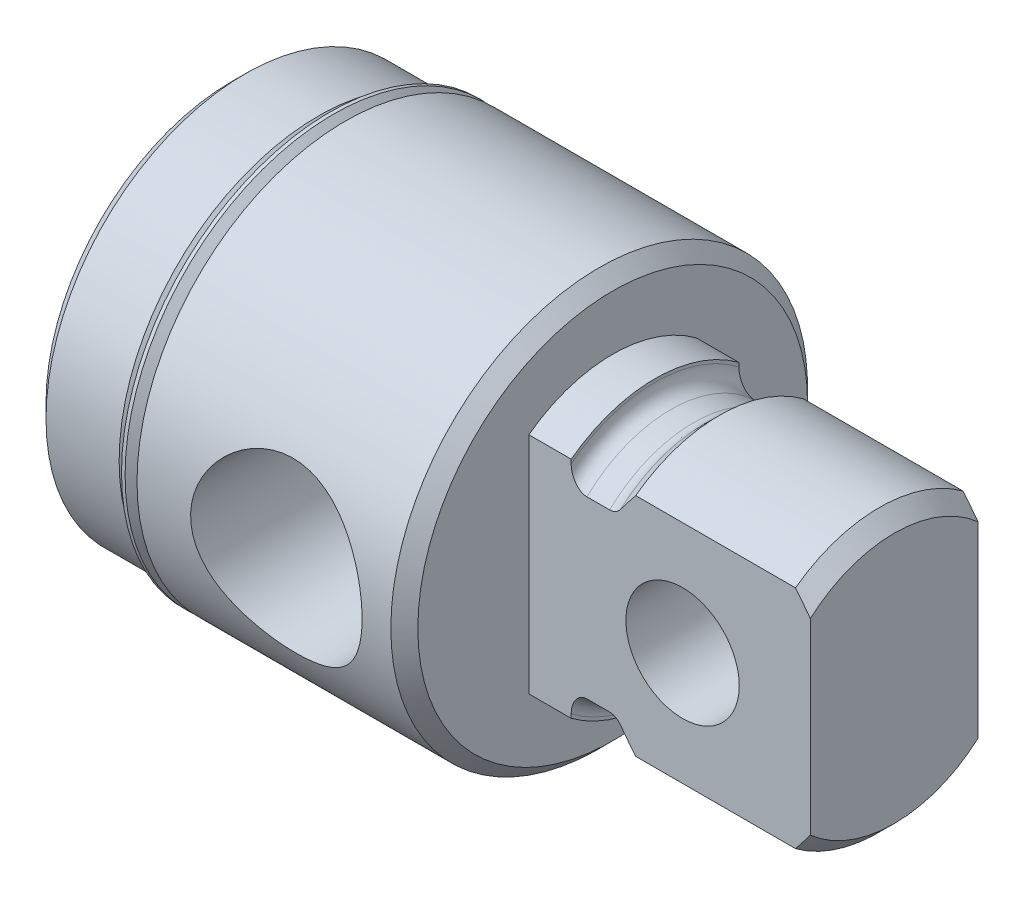
from build123d import *

# Parameters (mm, degrees)
SKETCH3_W               = 47.0408
SKETCH3_H               = 94.0816
SKETCH3_W_2             = 9.4615
SKETCH3_H_2             = 47.0408
CUT_EXTRUDE1_DEPTH      = 15.8877
HOLE1_D                 = 6.35
HOLE1_DEPTH             = 19.08302
HOLE1_TIP               = 1.833087105
SKETCH7_W               = 5.6642
SKETCH7_H               = 6.4135
CUT_EXTRUDE2_DEPTH      = 7.096125
CUT_EXTRUDE2_DEPTH_BACK = 7.096125
SKETCH9_R               = 3.2004


with BuildPart() as part:
    # Sketch1 → Revolve1 (revolve)
    with BuildSketch(Plane.XY):
        Polygon((0, 0), (0, 10.48385), (0.762, 11.24585), (4.8895, 11.24585), (5.6515, 10.48385), (6.4135, 10.48385), (6.4135, 11.7602), (20.7391, 11.7602), (21.5011, 10.9982), (21.5011, 0), align=None)
    revolve(axis=Axis((21.5011, 0, 0), (-1, 0, 0)))

    # Sketch2 → Revolve2 (revolve)
    with BuildSketch(Plane.XY):
        with BuildLine():
            Line((21.5011, 0), (21.5011, 7.90575))
            Line((21.5011, 7.90575), (23.8887, 7.90575))
            Line((23.8887, 7.90575), (23.8887, 7.72795))
            ThreePointArc((23.8887, 7.72795), (24.149082072, 7.099332072), (24.7777, 6.83895))
            Line((24.7777, 6.83895), (26.0604, 6.83895))
            ThreePointArc((26.0604, 6.83895), (26.38140348, 6.898927826), (26.65909292, 7.0707683))
            Line((26.65909292, 7.0707683), (26.689017928, 7.09803))
            Line((26.689017928, 7.09803), (27.528487928, 7.9375))
            Line((27.528487928, 7.9375), (36.54933, 7.9375))
            Line((36.54933, 7.9375), (37.3888, 7.09803))
            Line((37.3888, 7.09803), (37.3888, 0))
            Line((37.3888, 0), (21.5011, 0))
        make_face()
    revolve(axis=Axis((37.3888, 0, 0), (-1, 0, 0)))

    # Sketch3 → Cut-Extrude1 (cut)
    with BuildSketch(Plane(origin=(37.3888, 0, 0), x_dir=(0, 0, -1), z_dir=(1, 0, 0))):
        Rectangle(SKETCH3_W, SKETCH3_H)
        Rectangle(SKETCH3_W_2, SKETCH3_H_2, mode=Mode.SUBTRACT)
    extrude(amount=-CUT_EXTRUDE1_DEPTH, mode=Mode.SUBTRACT)

    # Hole1
    with Locations(Plane.ZY):
        with Locations((0, 0)):
            Hole(HOLE1_D / 2, depth=HOLE1_DEPTH)
            with Locations((0, 0, -(HOLE1_DEPTH + HOLE1_TIP / 2))):  # 120° drill point
                Cone(0, HOLE1_D / 2, HOLE1_TIP, mode=Mode.SUBTRACT)

    # Sketch6 → Cut-Revolve1 (revolve, cut)
    with BuildSketch(Plane(origin=(0, 0, 0), x_dir=(1, 0, 0), z_dir=(0, 0.9998476951563913, 0.01745240643728403))):
        Polygon((14.2748, 0), (18.843078009, 0), (18.843078009, -3.0734), (19.114275925, -11.7602), (14.2748, -11.7602), align=None)
    revolve(axis=Axis((14.2748, -0.20524379, 11.758408865), (0, 0.01745240643728403, -0.9998476951563913)), mode=Mode.SUBTRACT)

    # Sketch7 → Cut-Revolve2 (revolve, cut)
    with BuildSketch(Plane.XY):
        with Locations((2.8321, 3.20675)):
            Rectangle(SKETCH7_W, SKETCH7_H)
    revolve(axis=Axis((5.6642, 0, 0), (-1, 0, 0)), mode=Mode.SUBTRACT)

    # Sketch8 → Revolve3 (revolve)
    with BuildSketch(Plane.XY):
        with BuildLine():
            Line((5.53694893, 11.676031804), (6.291012806, 10.921967928))
            ThreePointArc((6.291012806, 10.921967928), (6.328210245, 10.832165367), (6.291012806, 10.742362806))
            Line((6.291012806, 10.742362806), (6.0325, 10.48385))
            Line((6.0325, 10.48385), (5.6515, 10.48385))
            Line((5.6515, 10.48385), (5.6515, 10.22985))
            Line((5.6515, 10.22985), (6.4135, 10.22985))
            Line((6.4135, 10.22985), (6.4135, 11.08684893))
            Line((6.4135, 11.08684893), (5.74014893, 11.7602))
            Line((5.74014893, 11.7602), (5.53694893, 11.7602))
            Line((5.53694893, 11.7602), (5.53694893, 11.676031804))
        make_face()
    revolve(axis=Axis((6.4135, 0, 0), (-1, 0, 0)))

    # Sketch9 → Cut-Extrude2 (cut, two sides: drawn at the far end of the back side and taken through both)
    with BuildSketch(Plane.XY.offset(-CUT_EXTRUDE2_DEPTH_BACK)):
        with Locations((30.1752, 0)):
            Circle(SKETCH9_R)
    extrude(amount=CUT_EXTRUDE2_DEPTH + CUT_EXTRUDE2_DEPTH_BACK, mode=Mode.SUBTRACT)


solid = part.part
